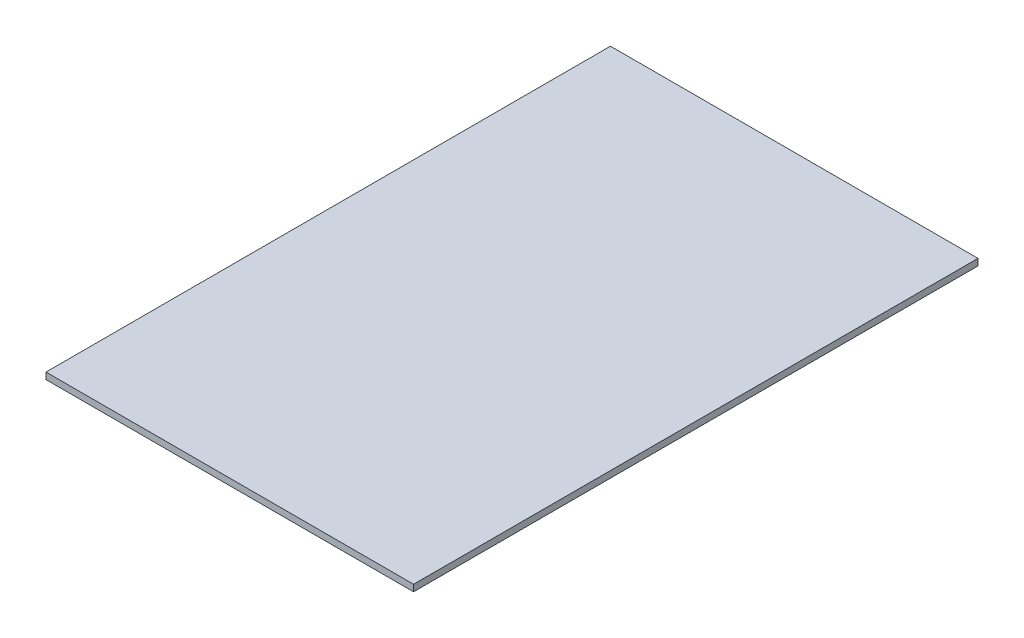
from build123d import *

# Parameters (mm, degrees)
CROQUIS1_W              = 140
CROQUIS1_H              = 275
SALIENTE_EXTRUIR1_DEPTH = 2.5
CROQUIS2_W              = 42
CROQUIS2_H              = 36
SALIENTE_EXTRUIR2_DEPTH = 1
CROQUIS3_W              = 140
CROQUIS3_H              = 60
CORTAR_EXTRUIR1_DEPTH   = 4.5


with BuildPart() as part:
    # Croquis1 → Saliente-Extruir1 (new body)
    with BuildSketch(Plane(origin=(0, 0, 0), x_dir=(1, 0, 0), z_dir=(0, 1, 0))):
        Rectangle(CROQUIS1_W, CROQUIS1_H)
    extrude(amount=SALIENTE_EXTRUIR1_DEPTH)

    # Croquis2 → Saliente-Extruir2 (add)
    with BuildSketch(Plane(origin=(0, 0, 0), x_dir=(-1, 0, 0), z_dir=(0, -1, 0))):
        with Locations((35, 0)):
            Rectangle(CROQUIS2_W, CROQUIS2_H)
        with Locations((-35, 0)):
            Rectangle(CROQUIS2_W, CROQUIS2_H)
    extrude(amount=SALIENTE_EXTRUIR2_DEPTH)

    # Croquis3 → Cortar-Extruir1 (cut, through all)
    with BuildSketch(Plane(origin=(0, 2.5, 0), x_dir=(1, 0, 0), z_dir=(0, 1, 0))):
        with Locations((0, 107.5)):
            Rectangle(CROQUIS3_W, CROQUIS3_H)
    extrude(amount=-CORTAR_EXTRUIR1_DEPTH, mode=Mode.SUBTRACT)


solid = part.part
